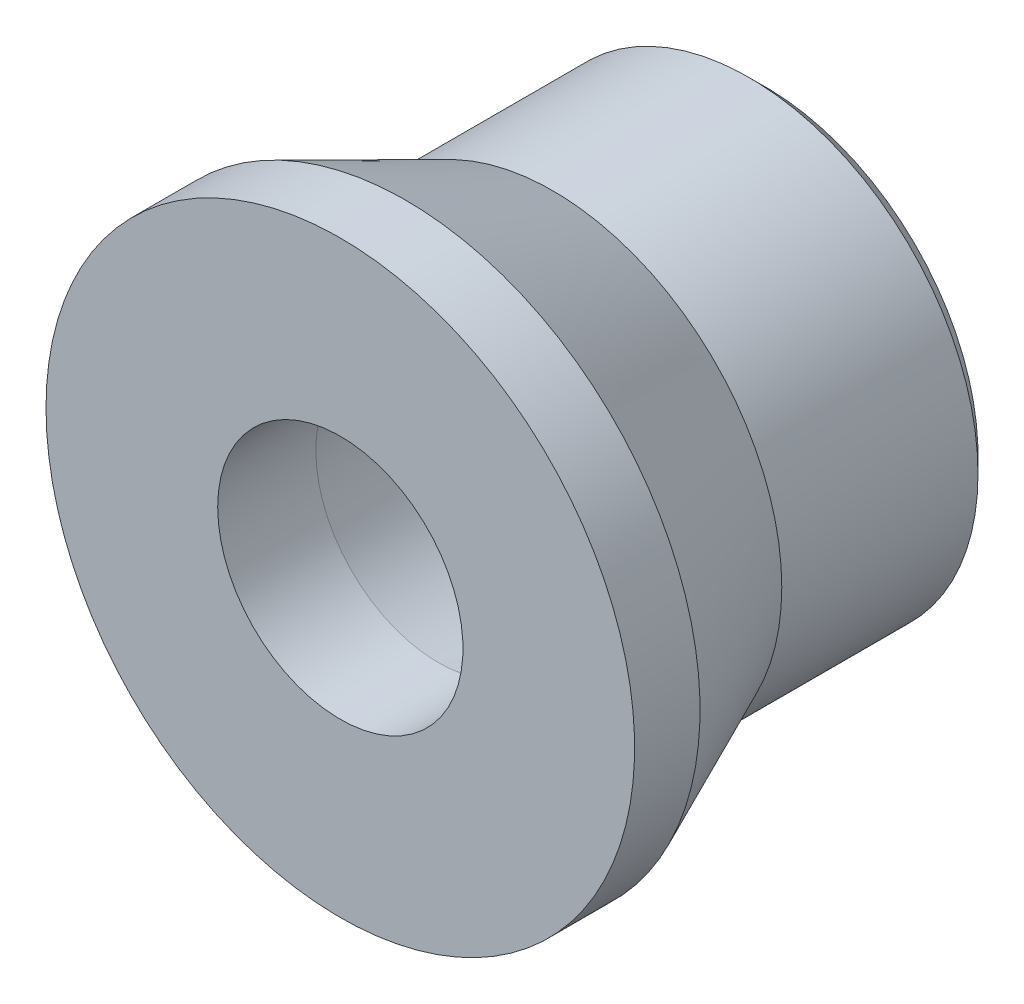
from build123d import *


with BuildPart() as part:
    # Sketch1 → Revolve1 (revolve)
    with BuildSketch(Plane.XZ):
        Polygon((7, 6.5), (9, 11), (9, 13), (3.750000001, 13), (3.750000001, 10), (4.999999999, 0), (6.5, 0), (7, 0.5), align=None)
    revolve(axis=Axis((0, 0, 13), (0, 0, -1)))


solid = part.part
